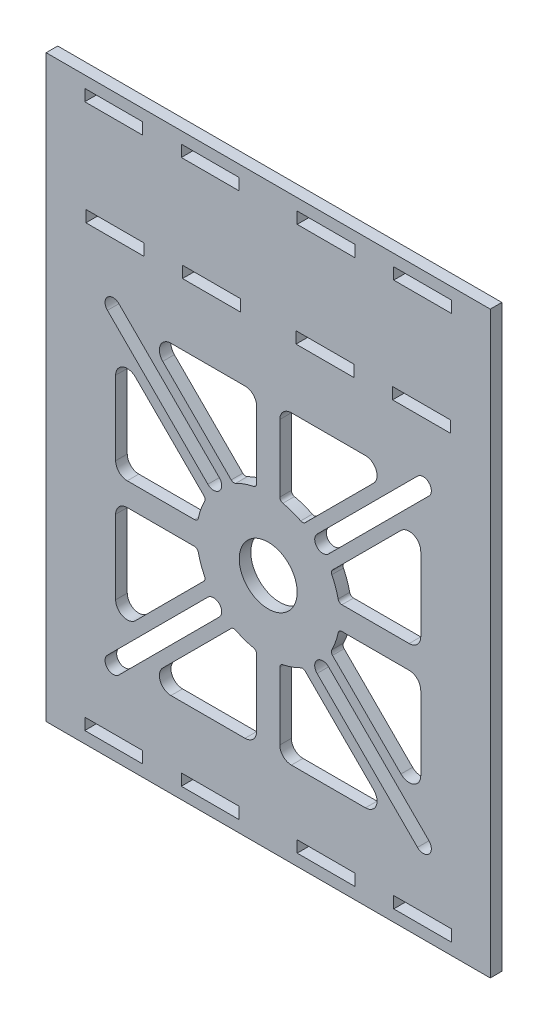
from build123d import *

# Parameters (mm, degrees)
SKETCH1_W           = 115
SKETCH1_H           = 150
SKETCH1_R           = 7.5
SKETCH1_W_2         = 15
SKETCH1_H_2         = 3
BOSS_EXTRUDE1_DEPTH = 3


with BuildPart() as part:
    # Sketch1 → Boss-Extrude1 (new body)
    with BuildSketch(Plane.XY):
        Rectangle(SKETCH1_W, SKETCH1_H)
        with Locations((0, -13.5)):
            Circle(SKETCH1_R, mode=Mode.SUBTRACT)
        with Locations((15, 70.5)):
            Rectangle(SKETCH1_W_2, SKETCH1_H_2, mode=Mode.SUBTRACT)
        with Locations((-40, 70.5)):
            Rectangle(SKETCH1_W_2, SKETCH1_H_2, mode=Mode.SUBTRACT)
        with Locations((-15, 70.5)):
            Rectangle(SKETCH1_W_2, SKETCH1_H_2, mode=Mode.SUBTRACT)
        with Locations((40, 70.5)):
            Rectangle(SKETCH1_W_2, SKETCH1_H_2, mode=Mode.SUBTRACT)
        with Locations((40, -70.5)):
            Rectangle(SKETCH1_W_2, SKETCH1_H_2, mode=Mode.SUBTRACT)
        with Locations((15, -70.5)):
            Rectangle(SKETCH1_W_2, SKETCH1_H_2, mode=Mode.SUBTRACT)
        with Locations((-15, -70.5)):
            Rectangle(SKETCH1_W_2, SKETCH1_H_2, mode=Mode.SUBTRACT)
        with Locations((-40, -70.5)):
            Rectangle(SKETCH1_W_2, SKETCH1_H_2, mode=Mode.SUBTRACT)
        with Locations((14.7, 43.5)):
            Rectangle(SKETCH1_W_2, SKETCH1_H_2, mode=Mode.SUBTRACT)
        with Locations((-39.7, 43.5)):
            Rectangle(SKETCH1_W_2, SKETCH1_H_2, mode=Mode.SUBTRACT)
        with Locations((-14.7, 43.5)):
            Rectangle(SKETCH1_W_2, SKETCH1_H_2, mode=Mode.SUBTRACT)
        with Locations((39.7, 43.5)):
            Rectangle(SKETCH1_W_2, SKETCH1_H_2, mode=Mode.SUBTRACT)
        with BuildLine():
            Line((39.5, -7.5), (39.5, 11.686291501))
            ThreePointArc((39.5, 11.686291501), (37.648050297, 14.457930099), (34.378679656, 13.807611845))
            Line((34.378679656, 13.807611845), (16.655175669, -3.915892143))
            ThreePointArc((16.655175669, -3.915892143), (16.374485428, -4.467252196), (16.471908992, -5.078229748))
            ThreePointArc((16.471908992, -5.078229748), (17.443347183, -7.33723771), (18.106599572, -9.705128205))
            ThreePointArc((18.106599572, -9.705128205), (18.454909512, -10.276250026), (19.085334684, -10.5))
            Line((19.085334684, -10.5), (36.5, -10.5))
            ThreePointArc((36.5, -10.5), (38.621320344, -9.621320344), (39.5, -7.5))
        make_face(mode=Mode.SUBTRACT)
        with BuildLine():
            Line((3, -32.585334684), (3, -50))
            ThreePointArc((3, -50), (3.878679656, -52.121320344), (6, -53))
            Line((6, -53), (25.186291501, -53))
            ThreePointArc((25.186291501, -53), (27.957930099, -51.148050297), (27.307611845, -47.878679656))
            Line((27.307611845, -47.878679656), (9.584107857, -30.155175669))
            ThreePointArc((9.584107857, -30.155175669), (9.032747804, -29.874485428), (8.421770252, -29.971908992))
            ThreePointArc((8.421770252, -29.971908992), (6.16276229, -30.943347183), (3.794871795, -31.606599572))
            ThreePointArc((3.794871795, -31.606599572), (3.223749974, -31.954909512), (3, -32.585334684))
        make_face(mode=Mode.SUBTRACT)
        with BuildLine():
            Line((16.655175669, -23.084107857), (34.378679656, -40.807611845))
            ThreePointArc((34.378679656, -40.807611845), (37.648050297, -41.457930099), (39.5, -38.686291501))
            Line((39.5, -38.686291501), (39.5, -19.5))
            ThreePointArc((39.5, -19.5), (38.621320344, -17.378679656), (36.5, -16.5))
            Line((36.5, -16.5), (19.085334684, -16.5))
            ThreePointArc((19.085334684, -16.5), (18.454909512, -16.723749974), (18.106599572, -17.294871795))
            ThreePointArc((18.106599572, -17.294871795), (17.443347183, -19.66276229), (16.471908992, -21.921770252))
            ThreePointArc((16.471908992, -21.921770252), (16.374485428, -22.532747804), (16.655175669, -23.084107857))
        make_face(mode=Mode.SUBTRACT)
        with BuildLine():
            Line((6, 26), (25.186291501, 26))
            ThreePointArc((25.186291501, 26), (27.957930099, 24.148050297), (27.307611845, 20.878679656))
            Line((27.307611845, 20.878679656), (9.584107857, 3.155175669))
            ThreePointArc((9.584107857, 3.155175669), (9.032747804, 2.874485428), (8.421770252, 2.971908992))
            ThreePointArc((8.421770252, 2.971908992), (6.16276229, 3.943347183), (3.794871795, 4.606599572))
            ThreePointArc((3.794871795, 4.606599572), (3.223749974, 4.954909512), (3, 5.585334684))
            Line((3, 5.585334684), (3, 23))
            ThreePointArc((3, 23), (3.878679656, 25.121320344), (6, 26))
        make_face(mode=Mode.SUBTRACT)
        with BuildLine():
            Line((-3, 5.585334684), (-3, 23))
            ThreePointArc((-3, 23), (-3.878679656, 25.121320344), (-6, 26))
            Line((-6, 26), (-25.186291501, 26))
            ThreePointArc((-25.186291501, 26), (-27.957930099, 24.148050297), (-27.307611845, 20.878679656))
            Line((-27.307611845, 20.878679656), (-9.584107857, 3.155175669))
            ThreePointArc((-9.584107857, 3.155175669), (-9.032747804, 2.874485428), (-8.421770252, 2.971908992))
            ThreePointArc((-8.421770252, 2.971908992), (-6.16276229, 3.943347183), (-3.794871795, 4.606599572))
            ThreePointArc((-3.794871795, 4.606599572), (-3.223749974, 4.954909512), (-3, 5.585334684))
        make_face(mode=Mode.SUBTRACT)
        with BuildLine():
            Line((-39.5, -7.5), (-39.5, 11.686291501))
            ThreePointArc((-39.5, 11.686291501), (-37.648050297, 14.457930099), (-34.378679656, 13.807611845))
            Line((-34.378679656, 13.807611845), (-16.655175669, -3.915892143))
            ThreePointArc((-16.655175669, -3.915892143), (-16.374485428, -4.467252196), (-16.471908992, -5.078229748))
            ThreePointArc((-16.471908992, -5.078229748), (-17.443347183, -7.33723771), (-18.106599572, -9.705128205))
            ThreePointArc((-18.106599572, -9.705128205), (-18.454909512, -10.276250026), (-19.085334684, -10.5))
            Line((-19.085334684, -10.5), (-36.5, -10.5))
            ThreePointArc((-36.5, -10.5), (-38.621320344, -9.621320344), (-39.5, -7.5))
        make_face(mode=Mode.SUBTRACT)
        with BuildLine():
            Line((-19.085334684, -16.5), (-36.5, -16.5))
            ThreePointArc((-36.5, -16.5), (-38.621320344, -17.378679656), (-39.5, -19.5))
            Line((-39.5, -19.5), (-39.5, -38.686291501))
            ThreePointArc((-39.5, -38.686291501), (-37.648050297, -41.457930099), (-34.378679656, -40.807611845))
            Line((-34.378679656, -40.807611845), (-16.655175669, -23.084107857))
            ThreePointArc((-16.655175669, -23.084107857), (-16.374485428, -22.532747804), (-16.471908992, -21.921770252))
            ThreePointArc((-16.471908992, -21.921770252), (-17.443347183, -19.66276229), (-18.106599572, -17.294871795))
            ThreePointArc((-18.106599572, -17.294871795), (-18.454909512, -16.723749974), (-19.085334684, -16.5))
        make_face(mode=Mode.SUBTRACT)
        with BuildLine():
            Line((-3, -32.585334684), (-3, -50))
            ThreePointArc((-3, -50), (-3.878679656, -52.121320344), (-6, -53))
            Line((-6, -53), (-25.186291501, -53))
            ThreePointArc((-25.186291501, -53), (-27.957930099, -51.148050297), (-27.307611845, -47.878679656))
            Line((-27.307611845, -47.878679656), (-9.584107857, -30.155175669))
            ThreePointArc((-9.584107857, -30.155175669), (-9.032747804, -29.874485428), (-8.421770252, -29.971908992))
            ThreePointArc((-8.421770252, -29.971908992), (-6.16276229, -30.943347183), (-3.794871795, -31.606599572))
            ThreePointArc((-3.794871795, -31.606599572), (-3.223749974, -31.954909512), (-3, -32.585334684))
        make_face(mode=Mode.SUBTRACT)
        with BuildLine():
            Line((12.657211383, 2.127059864), (38.658474042, 28.128322523))
            ThreePointArc((38.658474042, 28.128322523), (41.628322523, 28.128322523), (41.628322523, 25.158474042))
            Line((41.628322523, 25.158474042), (15.627059864, -0.842788617))
            ThreePointArc((15.627059864, -0.842788617), (12.657211383, -0.842788617), (12.657211383, 2.127059864))
        make_face(mode=Mode.SUBTRACT)
        with BuildLine():
            Line((12.657211383, -29.127059864), (38.658474042, -55.128322523))
            ThreePointArc((38.658474042, -55.128322523), (41.628322523, -55.128322523), (41.628322523, -52.158474042))
            Line((41.628322523, -52.158474042), (15.627059864, -26.157211383))
            ThreePointArc((15.627059864, -26.157211383), (12.657211383, -26.157211383), (12.657211383, -29.127059864))
        make_face(mode=Mode.SUBTRACT)
        with BuildLine():
            Line((-12.657211383, -29.127059864), (-38.658474042, -55.128322523))
            ThreePointArc((-38.658474042, -55.128322523), (-41.628322523, -55.128322523), (-41.628322523, -52.158474042))
            Line((-41.628322523, -52.158474042), (-15.627059864, -26.157211383))
            ThreePointArc((-15.627059864, -26.157211383), (-12.657211383, -26.157211383), (-12.657211383, -29.127059864))
        make_face(mode=Mode.SUBTRACT)
        with BuildLine():
            Line((-12.657211383, 2.127059864), (-38.658474042, 28.128322523))
            ThreePointArc((-38.658474042, 28.128322523), (-41.628322523, 28.128322523), (-41.628322523, 25.158474042))
            Line((-41.628322523, 25.158474042), (-15.627059864, -0.842788617))
            ThreePointArc((-15.627059864, -0.842788617), (-12.657211383, -0.842788617), (-12.657211383, 2.127059864))
        make_face(mode=Mode.SUBTRACT)
    extrude(amount=BOSS_EXTRUDE1_DEPTH)


solid = part.part
